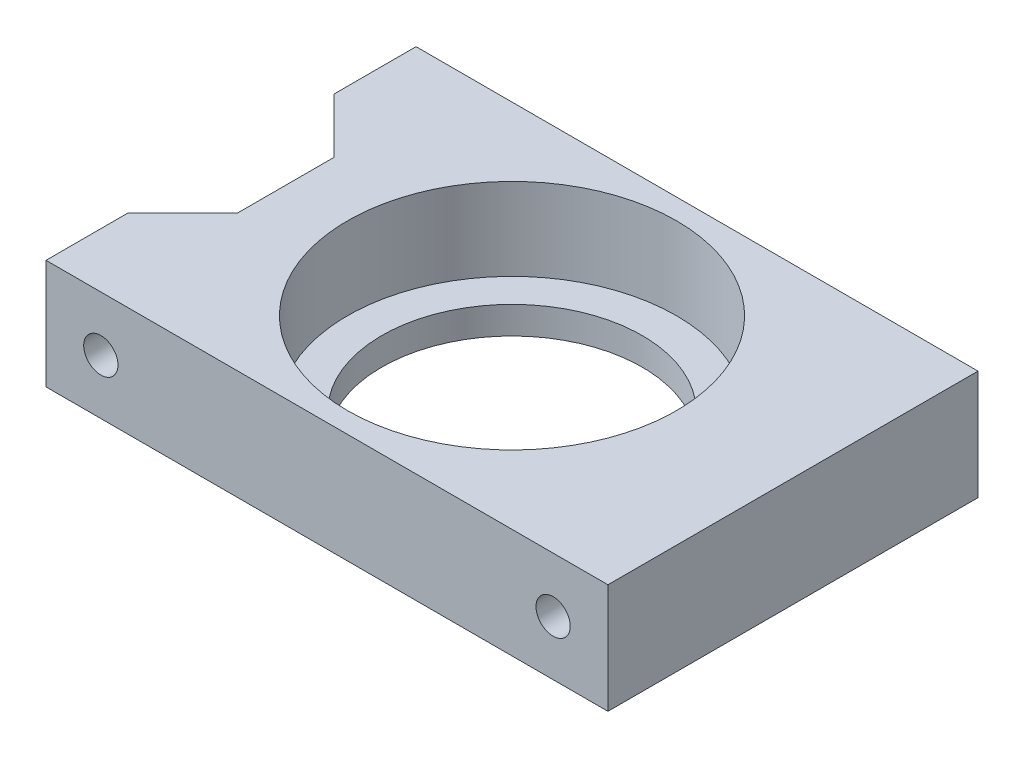
from build123d import *

# Parameters (mm, degrees)
SKETCH_1_W          = 41
SKETCH_1_H          = 27
SKETCH_1_R          = 9.5
EXTRUDE_1_DEPTH     = 8
SKETCH_2_R          = 12
CUT_EXTRUDE_1_DEPTH = 6
CUT_EXTRUDE_2_DEPTH = 8
SKETCH_4_R          = 1.25
CUT_EXTRUDE_3_DEPTH = 7
SKETCH_5_R          = 1.25
CUT_EXTRUDE_4_DEPTH = 7


with BuildPart() as part:
    # Эскиз1 → Бобышка-Вытянуть1 (new body)
    with BuildSketch(Plane(origin=(0, 0, 0), x_dir=(1, 0, 0), z_dir=(0, 1, 0))):
        Rectangle(SKETCH_1_W, SKETCH_1_H)
        with Locations(Location((0, 0, 0), (0, 0, 270))):  # turned: the seam where the file's is
            Circle(SKETCH_1_R, mode=Mode.SUBTRACT)
    extrude(amount=EXTRUDE_1_DEPTH)

    # Эскиз2 → Вырез-Вытянуть1 (cut)
    with BuildSketch(Plane(origin=(0, 8, 0), x_dir=(1, 0, 0), z_dir=(0, 1, 0))):
        with Locations(Location((0, 0, 0), (0, 0, 270))):  # turned: the seam where the file's is
            Circle(SKETCH_2_R)
    extrude(amount=-CUT_EXTRUDE_1_DEPTH, mode=Mode.SUBTRACT)

    # Эскиз3 → Вырез-Вытянуть2 (cut)
    with BuildSketch(Plane(origin=(0, 8, 0), x_dir=(1, 0, 0), z_dir=(0, 1, 0))):
        Polygon((-20.5, 7.5), (-16.5, 3.5), (-16.5, -3.5), (-20.5, -7.5), align=None)
    extrude(amount=-CUT_EXTRUDE_2_DEPTH, mode=Mode.SUBTRACT)

    # Эскиз4 → Вырез-Вытянуть3 (cut)
    with BuildSketch(Plane.XY.offset(13.5)):
        with Locations((-16.5, 4)):
            Circle(SKETCH_4_R)
        with Locations(Location((16.5, 4, 0), (0, 0, 180))):  # turned: the seam where the file's is
            Circle(SKETCH_4_R)
    extrude(amount=-CUT_EXTRUDE_3_DEPTH, mode=Mode.SUBTRACT)

    # Эскиз5 → Вырез-Вытянуть4 (cut)
    with BuildSketch(Plane(origin=(0, 0, -13.5), x_dir=(-1, 0, 0), z_dir=(0, 0, -1))):
        with Locations((-16.5, 4)):
            Circle(SKETCH_5_R)
        with Locations(Location((16.5, 4, 0), (0, 0, 180))):  # turned: the seam where the file's is
            Circle(SKETCH_5_R)
    extrude(amount=-CUT_EXTRUDE_4_DEPTH, mode=Mode.SUBTRACT)


solid = part.part
